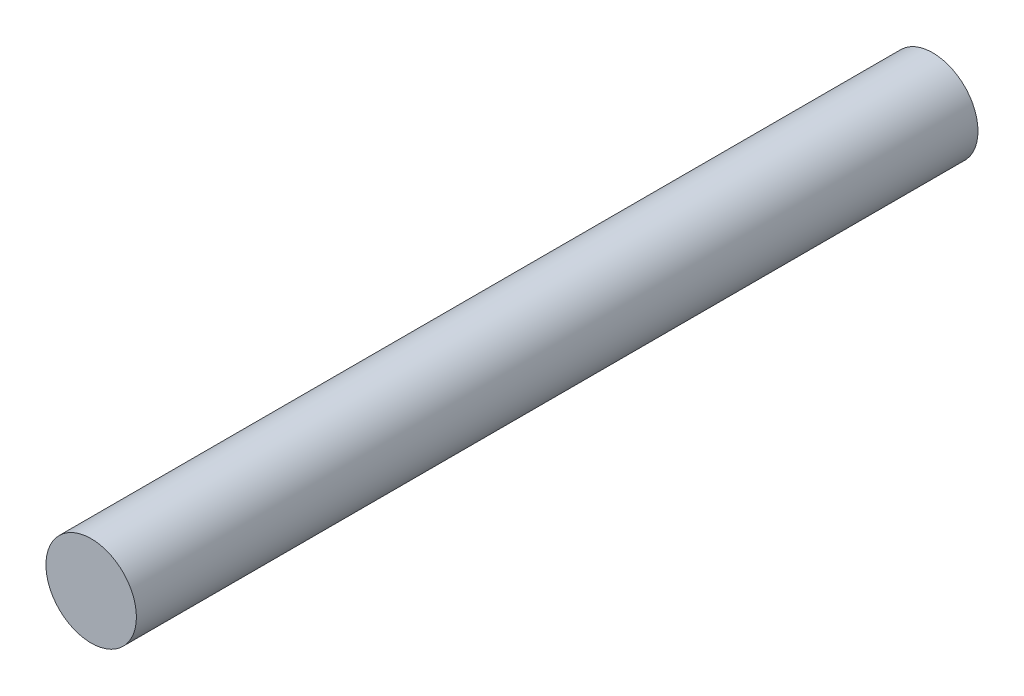
from build123d import *

# Parameters (mm, degrees)
SKETCH1_R           = 2.5
BOSS_EXTRUDE1_DEPTH = 46.5


with BuildPart() as part:
    # Sketch1 → Boss-Extrude1 (new body)
    with BuildSketch(Plane.XY):
        Circle(SKETCH1_R)
    extrude(amount=BOSS_EXTRUDE1_DEPTH)


solid = part.part
